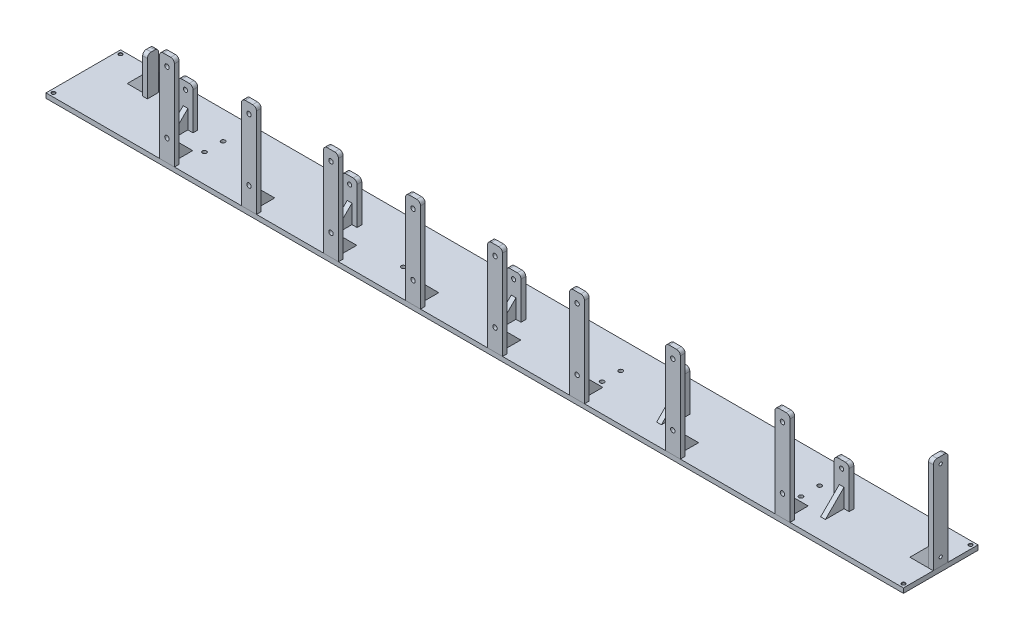
from build123d import *

# Parameters (mm, degrees)
ESQUISSE1_W                                   = 1150
ESQUISSE1_H                                   = 100
BOSS_EXTRU_1_DEPTH                            = 6.35
D_GAGEMENT_M52_D                              = 5.5
BOSS_EXTRU_4_DEPTH                            = 6.35
BOSS_EXTRU_5_DEPTH                            = 3.175
BOSS_EXTRU_2_DEPTH                            = 6.35
BOSS_EXTRU_3_DEPTH                            = 3.175
R_P_TITION_LIN_AIRE1_COUNT                    = 5
R_P_TITION_LIN_AIRE1_PITCH                    = 220
BOSS_EXTRU_6_DEPTH                            = 6.35
BOSS_EXTRU_6_2_DEPTH                          = 6.35
BOSS_EXTRU_6_3_DEPTH                          = 6.35
BOSS_EXTRU_6_4_DEPTH                          = 6.35
BOSS_EXTRU_6_5_DEPTH                          = 6.35
BOSS_EXTRU_6_6_DEPTH                          = 6.35
BOSS_EXTRU_6_7_DEPTH                          = 6.35
BOSS_EXTRU_6_8_DEPTH                          = 6.35
BOSS_EXTRU_7_DEPTH                            = 3.175
R_P_TITION_LIN_AIRE2_COUNT                    = 6
R_P_TITION_LIN_AIRE2_PITCH                    = 110
R_P_TITION_LIN_AIRE3_COUNT                    = 2
R_P_TITION_LIN_AIRE3_PITCH                    = 128.5
R_P_TITION_LIN_AIRE4_COUNT                    = 2
R_P_TITION_LIN_AIRE4_PITCH                    = 147
ESQUISSE18_W                                  = 3
ESQUISSE18_H                                  = 6.351
TROU_POUR_TARAUDAGE_POUR_TROU_TARAUD_2_COUNT  = 2
TROU_POUR_TARAUDAGE_POUR_TROU_TARAUD_2_PITCH  = 83
TROU_POUR_TARAUDAGE_POUR_TROU_TARAUD_3_COUNT  = 2
TROU_POUR_TARAUDAGE_POUR_TROU_TARAUD_3_PITCH  = 110
TROU_POUR_TARAUDAGE_POUR_TROU_TARAUD_4_COUNT  = 2
TROU_POUR_TARAUDAGE_POUR_TROU_TARAUD_4_PITCH  = 137.80058055
TROU_POUR_TARAUDAGE_POUR_TROU_TARAUD_5_COUNT  = 2
TROU_POUR_TARAUDAGE_POUR_TROU_TARAUD_5_PITCH  = 220
TROU_POUR_TARAUDAGE_POUR_TROU_TARAUD_6_COUNT  = 2
TROU_POUR_TARAUDAGE_POUR_TROU_TARAUD_6_PITCH  = 235.136130784
TROU_POUR_TARAUDAGE_POUR_TROU_TARAUD_7_COUNT  = 2
TROU_POUR_TARAUDAGE_POUR_TROU_TARAUD_7_PITCH  = 330
TROU_POUR_TARAUDAGE_POUR_TROU_TARAUD_8_COUNT  = 2
TROU_POUR_TARAUDAGE_POUR_TROU_TARAUD_8_PITCH  = 340.277827664
TROU_POUR_TARAUDAGE_POUR_TROU_TARAUD_9_COUNT  = 2
TROU_POUR_TARAUDAGE_POUR_TROU_TARAUD_9_PITCH  = 440
TROU_POUR_TARAUDAGE_POUR_TROU_TARAUD_10_COUNT = 2
TROU_POUR_TARAUDAGE_POUR_TROU_TARAUD_10_PITCH = 447.759980347
TROU_POUR_TARAUDAGE_POUR_TROU_TARAUD_11_COUNT = 2
TROU_POUR_TARAUDAGE_POUR_TROU_TARAUD_11_PITCH = 550
TROU_POUR_TARAUDAGE_POUR_TROU_TARAUD_12_COUNT = 2
TROU_POUR_TARAUDAGE_POUR_TROU_TARAUD_12_PITCH = 556.227471454
TROU_POUR_TARAUDAGE_POUR_TROU_TARAUD_13_COUNT = 2
TROU_POUR_TARAUDAGE_POUR_TROU_TARAUD_13_PITCH = 678.5
TROU_POUR_TARAUDAGE_POUR_TROU_TARAUD_14_COUNT = 2
TROU_POUR_TARAUDAGE_POUR_TROU_TARAUD_14_PITCH = 683.55778834
TROU_POUR_TARAUDAGE_POUR_TROU_TARAUD_15_COUNT = 2
TROU_POUR_TARAUDAGE_POUR_TROU_TARAUD_15_PITCH = 825.5
TROU_POUR_TARAUDAGE_POUR_TROU_TARAUD_16_COUNT = 2
TROU_POUR_TARAUDAGE_POUR_TROU_TARAUD_16_PITCH = 829.662130026
BOSS_EXTRU_8_DEPTH                            = 6.35
BOSS_EXTRU_9_START                            = 10
BOSS_EXTRU_9_DEPTH                            = 6.35
BOSS_EXTRU_10_START                           = -10
BOSS_EXTRU_10_DEPTH                           = 6.35
ESQUISSE22_W                                  = 2.1
ESQUISSE22_H                                  = 1018.175
TROU_TARAUD_M5X0_82_AT_2_COUNT                = 2
TROU_TARAUD_M5X0_82_AT_2_PITCH                = 108


with BuildPart() as part:
    # Esquisse1 → Boss.-Extru.1 (new body)
    with BuildSketch(Plane(origin=(0, 0, 0), x_dir=(1, 0, 0), z_dir=(0, 1, 0))):
        Rectangle(ESQUISSE1_W, ESQUISSE1_H)
    extrude(amount=BOSS_EXTRU_1_DEPTH)

    # Dégagement M52 (through all)
    with Locations(Plane(origin=(0, 6.35, 0), x_dir=(1, 0, 0), z_dir=(0, 1, 0))):
        with Locations((133.333333333, -12.5), (-400, 12.5), (400, 12.5), (400, -12.5), (-400, -12.5), (-133.333333333, -12.5), (-133.333333333, 12.5), (133.333333333, 12.5)):
            Hole(D_GAGEMENT_M52_D / 2)

    # Esquisse16 → Trou taraudé M5x0.81 (revolve, cut)
    with BuildSketch(Plane(origin=(570, 6.35, 45), x_dir=(0, 0, 1), z_dir=(1, 0, 0))):
        Polygon((0, 0), (0, 6.351), (2.1, 6.351), (2.1, 0.425), (2.525, 0), align=None)
    trou_taraud_m5x0_81 = revolve(axis=Axis((570, 12.7, 45), (0, -1, 0)), mode=Mode.SUBTRACT)

    # Symétrie1: Trou taraudé M5x0.81 across plane
    add(trou_taraud_m5x0_81.mirror(Plane.XY), mode=Mode.SUBTRACT)

    # Symétrie2: Trou taraudé M5x0.81 across plane
    add(trou_taraud_m5x0_81.mirror(Plane(origin=(0, 0, 0), x_dir=(0, 0, 1), z_dir=(1, 0, 0))), mode=Mode.SUBTRACT)

    # Symétrie2 copy 1 sketch → Symétrie2 copy 1 (revolve, cut)
    with BuildSketch(Plane(origin=(-570, 6.35, -45), x_dir=(0, 0, -1), z_dir=(-1, 0, 0))):
        Polygon((0, 0), (0, 6.351), (2.1, 6.351), (2.1, 0.425), (2.525, 0), align=None)
    revolve(axis=Axis((-570, 12.7, -45), (0, -1, 0)), mode=Mode.SUBTRACT)


with BuildPart() as body_2:
    # Esquisse5 → Boss.-Extru.4 (new body)
    with BuildSketch(Plane.ZY.offset(500)):
        with BuildLine():
            Line((-26, 6.35), (-11, 6.35))
            Line((-11, 6.35), (-11, 53.35))
            ThreePointArc((-11, 53.35), (-12.464466094, 56.885533906), (-16, 58.35))
            Line((-16, 58.35), (-21, 58.35))
            ThreePointArc((-21, 58.35), (-24.535533906, 56.885533906), (-26, 53.35))
            Line((-26, 53.35), (-26, 6.35))
        make_face()
    extrude(amount=BOSS_EXTRU_4_DEPTH)


with BuildPart() as body_3:
    # Esquisse6 → Boss.-Extru.5 (new, symmetric)
    with BuildSketch(Plane.XY.offset(-18.5)):
        Polygon((-506.35, 31.35), (-531.35, 6.35), (-506.35, 6.35), align=None)
    extrude(amount=BOSS_EXTRU_5_DEPTH, both=True)


with BuildPart() as body_4:
    # Esquisse2 → Boss.-Extru.2 (new body)
    with BuildSketch(Plane(origin=(0, 0, -8.5), x_dir=(-1, 0, 0), z_dir=(0, 0, -1))):
        with BuildLine():
            Line((450, 6.35), (430, 6.35))
            Line((430, 6.35), (430, 56.35))
            ThreePointArc((430, 56.35), (431.464466094, 59.885533906), (435, 61.35))
            Line((435, 61.35), (445, 61.35))
            ThreePointArc((445, 61.35), (448.535533906, 59.885533906), (450, 56.35))
            Line((450, 56.35), (450, 6.35))
        make_face()
    extrude(amount=-BOSS_EXTRU_2_DEPTH)

    # Esquisse8 → Dégagement M51 (revolve, cut)
    with BuildSketch(Plane(origin=(-440, 51.35, -2.15), x_dir=(0, -1, 0), z_dir=(1, 0, 0))):
        Polygon((0, 0), (0, 47.85), (2.75, 47.85), (2.75, 0.025), (2.775, 0), align=None)
    revolve(axis=Axis((-440, 51.35, 4.2), (0, 0, -1)), mode=Mode.SUBTRACT)


with BuildPart() as body_5:
    # Esquisse4 → Boss.-Extru.3 (new, symmetric)
    with BuildSketch(Plane(origin=(-440, 0, 0), x_dir=(0, 0, -1), z_dir=(1, 0, 0))):
        Polygon((2.15, 31.35), (-22.85, 6.35), (2.15, 6.35), align=None)
    extrude(amount=BOSS_EXTRU_3_DEPTH, both=True)


with BuildPart() as r_p_tition_lin_aire1_1:
    # Répétition linéaire1: pattern copy
    add(body_4.part.moved(Location(Vector(1, 0, 0) * (1 * R_P_TITION_LIN_AIRE1_PITCH))))


with BuildPart() as r_p_tition_lin_aire1_2:
    # Répétition linéaire1: pattern copy
    add(body_4.part.moved(Location(Vector(1, 0, 0) * (2 * R_P_TITION_LIN_AIRE1_PITCH))))


with BuildPart() as r_p_tition_lin_aire1_3:
    # Répétition linéaire1: pattern copy
    add(body_4.part.moved(Location(Vector(1, 0, 0) * (3 * R_P_TITION_LIN_AIRE1_PITCH))))


with BuildPart() as r_p_tition_lin_aire1_4:
    # Répétition linéaire1: pattern copy
    add(body_4.part.moved(Location(Vector(1, 0, 0) * (4 * R_P_TITION_LIN_AIRE1_PITCH))))


with BuildPart() as r_p_tition_lin_aire1_5:
    # Répétition linéaire1: pattern copy
    add(body_5.part.moved(Location(Vector(1, 0, 0) * (1 * R_P_TITION_LIN_AIRE1_PITCH))))


with BuildPart() as r_p_tition_lin_aire1_6:
    # Répétition linéaire1: pattern copy
    add(body_5.part.moved(Location(Vector(1, 0, 0) * (2 * R_P_TITION_LIN_AIRE1_PITCH))))


with BuildPart() as r_p_tition_lin_aire1_7:
    # Répétition linéaire1: pattern copy
    add(body_5.part.moved(Location(Vector(1, 0, 0) * (3 * R_P_TITION_LIN_AIRE1_PITCH))))


with BuildPart() as r_p_tition_lin_aire1_8:
    # Répétition linéaire1: pattern copy
    add(body_5.part.moved(Location(Vector(1, 0, 0) * (4 * R_P_TITION_LIN_AIRE1_PITCH))))


with BuildPart() as body_14:
    # Esquisse12 → Boss.-Extru.6 (new body)
    with BuildSketch(Plane.XY.offset(50)):
        with BuildLine():
            Line((-422.75, 6.35), (-402.75, 6.35))
            Line((-402.75, 6.35), (-402.75, 126.35))
            ThreePointArc((-402.75, 126.35), (-404.214466094, 129.885533906), (-407.75, 131.35))
            Line((-407.75, 131.35), (-417.75, 131.35))
            ThreePointArc((-417.75, 131.35), (-421.285533906, 129.885533906), (-422.75, 126.35))
            Line((-422.75, 126.35), (-422.75, 6.35))
        make_face()
    extrude(amount=-BOSS_EXTRU_6_DEPTH)

    # Esquisse18 → Trou pour taraudage pour trou taraudé M7x1.01 (revolve, cut)
    with BuildSketch(Plane(origin=(-412.75, 118, 50), x_dir=(0, -1, 0), z_dir=(1, 0, 0))):
        with Locations((1.5, 3.1755)):
            Rectangle(ESQUISSE18_W, ESQUISSE18_H)
    trou_pour_taraudage_pour_trou_taraud_m7 = revolve(axis=Axis((-412.75, 118, 56.35), (0, 0, -1)), mode=Mode.SUBTRACT)

    # Trou pour taraudage pour trou taraud 2: Trou pour taraudage pour trou taraudé M7x1.01 ×2
    with Locations(*[(0, -i * TROU_POUR_TARAUDAGE_POUR_TROU_TARAUD_2_PITCH, 0) for i in range(1, TROU_POUR_TARAUDAGE_POUR_TROU_TARAUD_2_COUNT)]):
        add(trou_pour_taraudage_pour_trou_taraud_m7, mode=Mode.SUBTRACT)


with BuildPart() as body_15:
    # Esquisse12 → Boss.-Extru.6 2 (new body)
    with BuildSketch(Plane.XY.offset(50)):
        with BuildLine():
            Line((-312.75, 6.35), (-292.75, 6.35))
            Line((-292.75, 6.35), (-292.75, 126.35))
            ThreePointArc((-292.75, 126.35), (-294.214466094, 129.885533906), (-297.75, 131.35))
            Line((-297.75, 131.35), (-307.75, 131.35))
            ThreePointArc((-307.75, 131.35), (-311.285533906, 129.885533906), (-312.75, 126.35))
            Line((-312.75, 126.35), (-312.75, 6.35))
        make_face()
    extrude(amount=-BOSS_EXTRU_6_2_DEPTH)

    # Trou pour taraudage pour trou taraud 3: Trou pour taraudage pour trou taraudé M7x1.01 ×2
    with Locations(*[(i * TROU_POUR_TARAUDAGE_POUR_TROU_TARAUD_3_PITCH, 0, 0) for i in range(1, TROU_POUR_TARAUDAGE_POUR_TROU_TARAUD_3_COUNT)]):
        add(trou_pour_taraudage_pour_trou_taraud_m7, mode=Mode.SUBTRACT)

    # Trou pour taraudage pour trou taraud 4: Trou pour taraudage pour trou taraudé M7x1.01 ×2
    with Locations(*[Vector(0.7982549823862822, -0.6023196685278311, 0) * (i * TROU_POUR_TARAUDAGE_POUR_TROU_TARAUD_4_PITCH) for i in range(1, TROU_POUR_TARAUDAGE_POUR_TROU_TARAUD_4_COUNT)]):
        add(trou_pour_taraudage_pour_trou_taraud_m7, mode=Mode.SUBTRACT)


with BuildPart() as body_16:
    # Esquisse12 → Boss.-Extru.6 3 (new body)
    with BuildSketch(Plane.XY.offset(50)):
        with BuildLine():
            Line((-202.75, 6.35), (-182.75, 6.35))
            Line((-182.75, 6.35), (-182.75, 126.35))
            ThreePointArc((-182.75, 126.35), (-184.214466094, 129.885533906), (-187.75, 131.35))
            Line((-187.75, 131.35), (-197.75, 131.35))
            ThreePointArc((-197.75, 131.35), (-201.285533906, 129.885533906), (-202.75, 126.35))
            Line((-202.75, 126.35), (-202.75, 6.35))
        make_face()
    extrude(amount=-BOSS_EXTRU_6_3_DEPTH)

    # Trou pour taraudage pour trou taraud 5: Trou pour taraudage pour trou taraudé M7x1.01 ×2
    with Locations(*[(i * TROU_POUR_TARAUDAGE_POUR_TROU_TARAUD_5_PITCH, 0, 0) for i in range(1, TROU_POUR_TARAUDAGE_POUR_TROU_TARAUD_5_COUNT)]):
        add(trou_pour_taraudage_pour_trou_taraud_m7, mode=Mode.SUBTRACT)

    # Trou pour taraudage pour trou taraud 6: Trou pour taraudage pour trou taraudé M7x1.01 ×2
    with Locations(*[Vector(0.9356282221137494, -0.3529870110701874, 0) * (i * TROU_POUR_TARAUDAGE_POUR_TROU_TARAUD_6_PITCH) for i in range(1, TROU_POUR_TARAUDAGE_POUR_TROU_TARAUD_6_COUNT)]):
        add(trou_pour_taraudage_pour_trou_taraud_m7, mode=Mode.SUBTRACT)


with BuildPart() as body_17:
    # Esquisse12 → Boss.-Extru.6 4 (new body)
    with BuildSketch(Plane.XY.offset(50)):
        with BuildLine():
            Line((-92.75, 6.35), (-72.75, 6.35))
            Line((-72.75, 6.35), (-72.75, 126.35))
            ThreePointArc((-72.75, 126.35), (-74.214466094, 129.885533906), (-77.75, 131.35))
            Line((-77.75, 131.35), (-87.75, 131.35))
            ThreePointArc((-87.75, 131.35), (-91.285533906, 129.885533906), (-92.75, 126.35))
            Line((-92.75, 126.35), (-92.75, 6.35))
        make_face()
    extrude(amount=-BOSS_EXTRU_6_4_DEPTH)

    # Trou pour taraudage pour trou taraud 7: Trou pour taraudage pour trou taraudé M7x1.01 ×2
    with Locations(*[(i * TROU_POUR_TARAUDAGE_POUR_TROU_TARAUD_7_PITCH, 0, 0) for i in range(1, TROU_POUR_TARAUDAGE_POUR_TROU_TARAUD_7_COUNT)]):
        add(trou_pour_taraudage_pour_trou_taraud_m7, mode=Mode.SUBTRACT)

    # Trou pour taraudage pour trou taraud 8: Trou pour taraudage pour trou taraudé M7x1.01 ×2
    with Locations(*[Vector(0.9697957761898841, -0.24391833158715273, 0) * (i * TROU_POUR_TARAUDAGE_POUR_TROU_TARAUD_8_PITCH) for i in range(1, TROU_POUR_TARAUDAGE_POUR_TROU_TARAUD_8_COUNT)]):
        add(trou_pour_taraudage_pour_trou_taraud_m7, mode=Mode.SUBTRACT)


with BuildPart() as body_18:
    # Esquisse12 → Boss.-Extru.6 5 (new body)
    with BuildSketch(Plane.XY.offset(50)):
        with BuildLine():
            Line((17.25, 6.35), (37.25, 6.35))
            Line((37.25, 6.35), (37.25, 126.35))
            ThreePointArc((37.25, 126.35), (35.785533906, 129.885533906), (32.25, 131.35))
            Line((32.25, 131.35), (22.25, 131.35))
            ThreePointArc((22.25, 131.35), (18.714466094, 129.885533906), (17.25, 126.35))
            Line((17.25, 126.35), (17.25, 6.35))
        make_face()
    extrude(amount=-BOSS_EXTRU_6_5_DEPTH)

    # Trou pour taraudage pour trou taraud 9: Trou pour taraudage pour trou taraudé M7x1.01 ×2
    with Locations(*[(i * TROU_POUR_TARAUDAGE_POUR_TROU_TARAUD_9_PITCH, 0, 0) for i in range(1, TROU_POUR_TARAUDAGE_POUR_TROU_TARAUD_9_COUNT)]):
        add(trou_pour_taraudage_pour_trou_taraud_m7, mode=Mode.SUBTRACT)

    # Trou pour taraudage pour trou taraud 10: Trou pour taraudage pour trou taraudé M7x1.01 ×2
    with Locations(*[Vector(0.982669330250089, -0.18536716911535772, 0) * (i * TROU_POUR_TARAUDAGE_POUR_TROU_TARAUD_10_PITCH) for i in range(1, TROU_POUR_TARAUDAGE_POUR_TROU_TARAUD_10_COUNT)]):
        add(trou_pour_taraudage_pour_trou_taraud_m7, mode=Mode.SUBTRACT)


with BuildPart() as body_19:
    # Esquisse12 → Boss.-Extru.6 6 (new body)
    with BuildSketch(Plane.XY.offset(50)):
        with BuildLine():
            Line((127.25, 6.35), (147.25, 6.35))
            Line((147.25, 6.35), (147.25, 126.35))
            ThreePointArc((147.25, 126.35), (145.785533906, 129.885533906), (142.25, 131.35))
            Line((142.25, 131.35), (132.25, 131.35))
            ThreePointArc((132.25, 131.35), (128.714466094, 129.885533906), (127.25, 126.35))
            Line((127.25, 126.35), (127.25, 6.35))
        make_face()
    extrude(amount=-BOSS_EXTRU_6_6_DEPTH)

    # Trou pour taraudage pour trou taraud 11: Trou pour taraudage pour trou taraudé M7x1.01 ×2
    with Locations(*[(i * TROU_POUR_TARAUDAGE_POUR_TROU_TARAUD_11_PITCH, 0, 0) for i in range(1, TROU_POUR_TARAUDAGE_POUR_TROU_TARAUD_11_COUNT)]):
        add(trou_pour_taraudage_pour_trou_taraud_m7, mode=Mode.SUBTRACT)

    # Trou pour taraudage pour trou taraud 12: Trou pour taraudage pour trou taraudé M7x1.01 ×2
    with Locations(*[Vector(0.9888040922581134, -0.14921952664986077, 0) * (i * TROU_POUR_TARAUDAGE_POUR_TROU_TARAUD_12_PITCH) for i in range(1, TROU_POUR_TARAUDAGE_POUR_TROU_TARAUD_12_COUNT)]):
        add(trou_pour_taraudage_pour_trou_taraud_m7, mode=Mode.SUBTRACT)


with BuildPart() as body_20:
    # Esquisse12 → Boss.-Extru.6 7 (new body)
    with BuildSketch(Plane.XY.offset(50)):
        with BuildLine():
            Line((255.75, 6.35), (275.75, 6.35))
            Line((275.75, 6.35), (275.75, 126.35))
            ThreePointArc((275.75, 126.35), (274.285533906, 129.885533906), (270.75, 131.35))
            Line((270.75, 131.35), (260.75, 131.35))
            ThreePointArc((260.75, 131.35), (257.214466094, 129.885533906), (255.75, 126.35))
            Line((255.75, 126.35), (255.75, 6.35))
        make_face()
    extrude(amount=-BOSS_EXTRU_6_7_DEPTH)

    # Trou pour taraudage pour trou taraud 13: Trou pour taraudage pour trou taraudé M7x1.01 ×2
    with Locations(*[(i * TROU_POUR_TARAUDAGE_POUR_TROU_TARAUD_13_PITCH, 0, 0) for i in range(1, TROU_POUR_TARAUDAGE_POUR_TROU_TARAUD_13_COUNT)]):
        add(trou_pour_taraudage_pour_trou_taraud_m7, mode=Mode.SUBTRACT)

    # Trou pour taraudage pour trou taraud 14: Trou pour taraudage pour trou taraudé M7x1.01 ×2
    with Locations(*[Vector(0.992600788951458, -0.12142353055706855, 0) * (i * TROU_POUR_TARAUDAGE_POUR_TROU_TARAUD_14_PITCH) for i in range(1, TROU_POUR_TARAUDAGE_POUR_TROU_TARAUD_14_COUNT)]):
        add(trou_pour_taraudage_pour_trou_taraud_m7, mode=Mode.SUBTRACT)


with BuildPart() as body_21:
    # Esquisse12 → Boss.-Extru.6 8 (new body)
    with BuildSketch(Plane.XY.offset(50)):
        with BuildLine():
            Line((402.75, 6.35), (422.75, 6.35))
            Line((422.75, 6.35), (422.75, 126.35))
            ThreePointArc((422.75, 126.35), (421.285533906, 129.885533906), (417.75, 131.35))
            Line((417.75, 131.35), (407.75, 131.35))
            ThreePointArc((407.75, 131.35), (404.214466094, 129.885533906), (402.75, 126.35))
            Line((402.75, 126.35), (402.75, 6.35))
        make_face()
    extrude(amount=-BOSS_EXTRU_6_8_DEPTH)

    # Trou pour taraudage pour trou taraud 15: Trou pour taraudage pour trou taraudé M7x1.01 ×2
    with Locations(*[(i * TROU_POUR_TARAUDAGE_POUR_TROU_TARAUD_15_PITCH, 0, 0) for i in range(1, TROU_POUR_TARAUDAGE_POUR_TROU_TARAUD_15_COUNT)]):
        add(trou_pour_taraudage_pour_trou_taraud_m7, mode=Mode.SUBTRACT)

    # Trou pour taraudage pour trou taraud 16: Trou pour taraudage pour trou taraudé M7x1.01 ×2
    with Locations(*[Vector(0.9949833433685811, -0.10004072380326133, 0) * (i * TROU_POUR_TARAUDAGE_POUR_TROU_TARAUD_16_PITCH) for i in range(1, TROU_POUR_TARAUDAGE_POUR_TROU_TARAUD_16_COUNT)]):
        add(trou_pour_taraudage_pour_trou_taraud_m7, mode=Mode.SUBTRACT)


with BuildPart() as body_22:
    # Esquisse14 → Boss.-Extru.7 (new, symmetric)
    with BuildSketch(Plane.ZY.offset(412.75)):
        Polygon((43.65, 31.35), (43.65, 6.35), (18.65, 6.35), align=None)
    extrude(amount=BOSS_EXTRU_7_DEPTH, both=True)


with BuildPart() as r_p_tition_lin_aire2_1:
    # Répétition linéaire2: pattern copy
    add(body_22.part.moved(Location(Vector(1, 0, 0) * (1 * R_P_TITION_LIN_AIRE2_PITCH))))


with BuildPart() as r_p_tition_lin_aire2_2:
    # Répétition linéaire2: pattern copy
    add(body_22.part.moved(Location(Vector(1, 0, 0) * (2 * R_P_TITION_LIN_AIRE2_PITCH))))


with BuildPart() as r_p_tition_lin_aire2_3:
    # Répétition linéaire2: pattern copy
    add(body_22.part.moved(Location(Vector(1, 0, 0) * (3 * R_P_TITION_LIN_AIRE2_PITCH))))


with BuildPart() as r_p_tition_lin_aire2_4:
    # Répétition linéaire2: pattern copy
    add(body_22.part.moved(Location(Vector(1, 0, 0) * (4 * R_P_TITION_LIN_AIRE2_PITCH))))


with BuildPart() as r_p_tition_lin_aire2_5:
    # Répétition linéaire2: pattern copy
    add(body_22.part.moved(Location(Vector(1, 0, 0) * (5 * R_P_TITION_LIN_AIRE2_PITCH))))


with BuildPart() as r_p_tition_lin_aire3_1:
    # Répétition linéaire3: pattern copy
    add(r_p_tition_lin_aire2_5.part.moved(Location(Vector(1, 0, 0) * (1 * R_P_TITION_LIN_AIRE3_PITCH))))


with BuildPart() as r_p_tition_lin_aire4_1:
    # Répétition linéaire4: pattern copy
    add(r_p_tition_lin_aire3_1.part.moved(Location(Vector(1, 0, 0) * (1 * R_P_TITION_LIN_AIRE4_PITCH))))


with BuildPart() as body_30:
    # Esquisse19 → Boss.-Extru.8 (new body)
    with BuildSketch(Plane(origin=(575, 0, 0), x_dir=(0, 0, -1), z_dir=(1, 0, 0))):
        with BuildLine():
            Line((-10, 6.35), (10, 6.35))
            Line((10, 6.35), (10, 129.35))
            ThreePointArc((10, 129.35), (8.535533906, 132.885533906), (5, 134.35))
            Line((5, 134.35), (-5, 134.35))
            ThreePointArc((-5, 134.35), (-8.535533906, 132.885533906), (-10, 129.35))
            Line((-10, 129.35), (-10, 6.35))
        make_face()
    extrude(amount=-BOSS_EXTRU_8_DEPTH)

    # Esquisse22 → Trou taraudé M5x0.82 (revolve, cut)
    with BuildSketch(Plane(origin=(575, 17.35, 0), x_dir=(0, 0, -1), z_dir=(0, 1, 0))):
        with Locations((1.05, 509.0875)):
            Rectangle(ESQUISSE22_W, ESQUISSE22_H)
    trou_taraud_m5x0_82 = revolve(axis=Axis((581.35, 17.35, 0), (-1, 0, 0)), mode=Mode.SUBTRACT)

    # Trou taraudé M5x0.82 at 2: Trou taraudé M5x0.82 ×2
    with Locations(*[(0, i * TROU_TARAUD_M5X0_82_AT_2_PITCH, 0) for i in range(1, TROU_TARAUD_M5X0_82_AT_2_COUNT)]):
        add(trou_taraud_m5x0_82, mode=Mode.SUBTRACT)


with BuildPart() as body_31:
    # Esquisse20 → Boss.-Extru.9 (new body)
    with BuildSketch(Plane.XY.offset(BOSS_EXTRU_9_START)):
        Polygon((568.65, 31.35), (543.65, 6.35), (568.65, 6.35), align=None)
    extrude(amount=-BOSS_EXTRU_9_DEPTH)


with BuildPart() as body_32:
    # Esquisse20_2 → Boss.-Extru.10 (new body)
    with BuildSketch(Plane.XY.offset(BOSS_EXTRU_10_START)):
        Polygon((568.65, 31.35), (543.65, 6.35), (568.65, 6.35), align=None)
    extrude(amount=BOSS_EXTRU_10_DEPTH)


solid = Compound([part.part, body_2.part, body_3.part, body_4.part, body_5.part, r_p_tition_lin_aire1_1.part, r_p_tition_lin_aire1_2.part, r_p_tition_lin_aire1_3.part, r_p_tition_lin_aire1_4.part, r_p_tition_lin_aire1_5.part, r_p_tition_lin_aire1_6.part, r_p_tition_lin_aire1_7.part, r_p_tition_lin_aire1_8.part, body_14.part, body_15.part, body_16.part, body_17.part, body_18.part, body_19.part, body_20.part, body_21.part, body_22.part, r_p_tition_lin_aire2_1.part, r_p_tition_lin_aire2_2.part, r_p_tition_lin_aire2_3.part, r_p_tition_lin_aire2_4.part, r_p_tition_lin_aire2_5.part, r_p_tition_lin_aire3_1.part, r_p_tition_lin_aire4_1.part, body_30.part, body_31.part, body_32.part])
